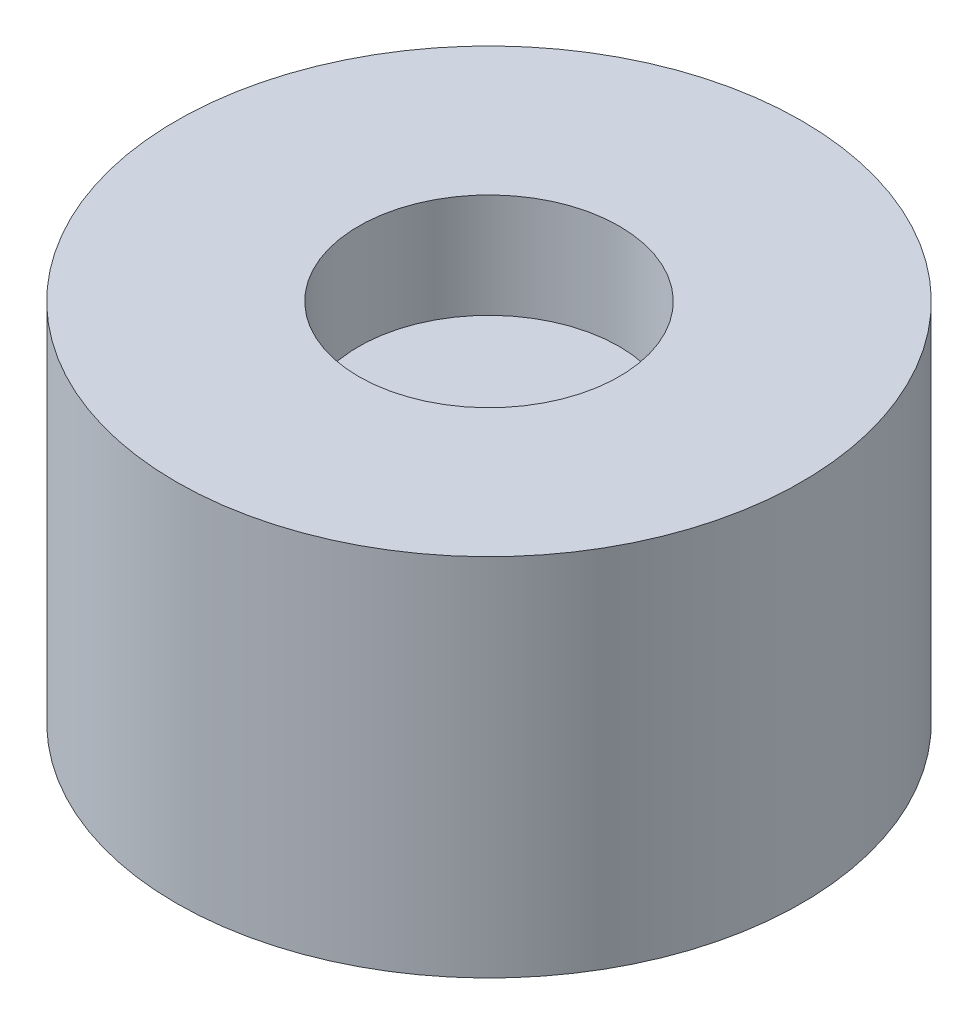
from build123d import *

# Parameters (mm, degrees)
SKETCH1_R           = 6
BOSS_EXTRUDE1_DEPTH = 7
SKETCH2_R           = 2.5
CUT_EXTRUDE1_DEPTH  = 2
SKETCH4_R           = 1
CUT_EXTRUDE3_DEPTH  = 2
FILLET1_R           = 1


with BuildPart() as part:
    # Sketch1 → Boss-Extrude1 (new body)
    with BuildSketch(Plane(origin=(0, 0, 0), x_dir=(1, 0, 0), z_dir=(0, 1, 0))):
        Circle(SKETCH1_R)
    extrude(amount=BOSS_EXTRUDE1_DEPTH)

    # Sketch2 → Cut-Extrude1 (cut)
    with BuildSketch(Plane(origin=(0, 7, 0), x_dir=(1, 0, 0), z_dir=(0, 1, 0))):
        Circle(SKETCH2_R)
    extrude(amount=-CUT_EXTRUDE1_DEPTH, mode=Mode.SUBTRACT)

    # Sketch4 → Cut-Extrude3 (cut)
    with BuildSketch(Plane.XZ):
        Circle(SKETCH4_R)
    extrude(amount=-CUT_EXTRUDE3_DEPTH, mode=Mode.SUBTRACT)

    # Fillet1
    fillet1_edges = [part.edges().sort_by_distance(p)[0] for p in [
        (-1, 2, 0),
    ]]
    fillet(fillet1_edges, radius=FILLET1_R)


solid = part.part
